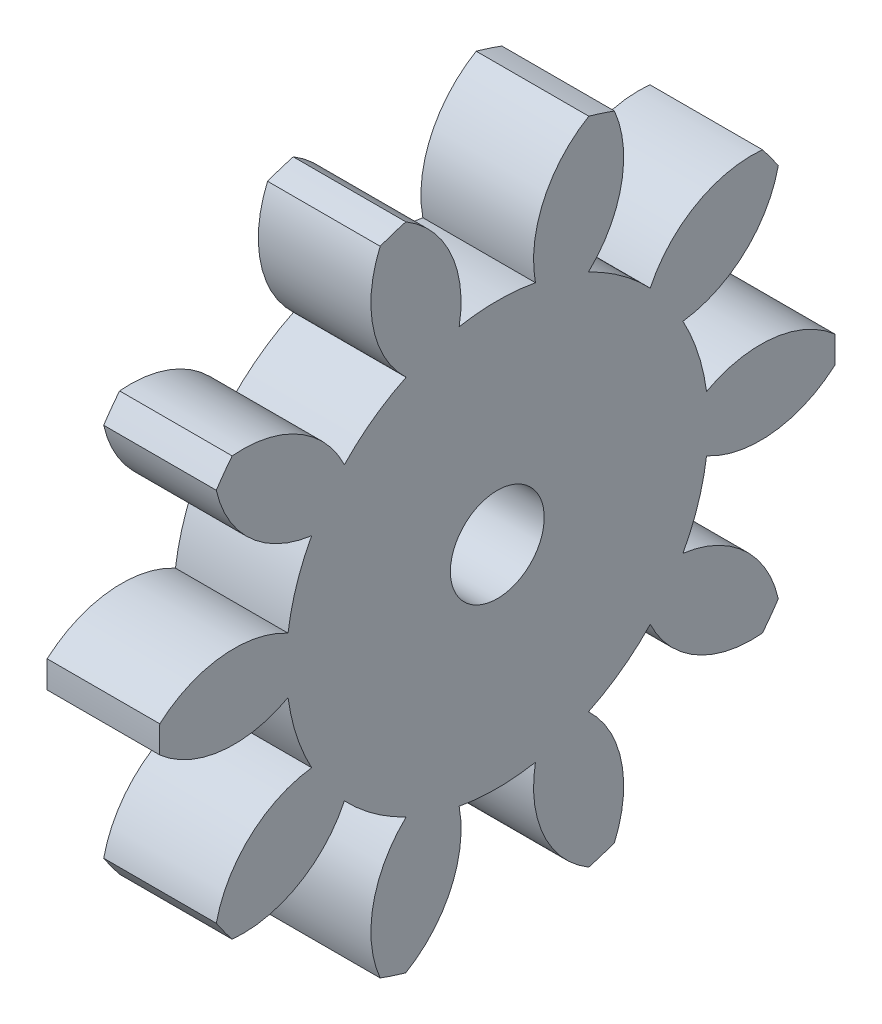
from build123d import *

# Parameters (mm, degrees)
BASPROSKE_W     = 6
BASPROSKE_H     = 18
TOOTHCUT_DEPTH  = 27.153393661
TEETHCUTS_COUNT = 10
TEETHCUTS_ANGLE = 324
BORSKE_R        = 2.5
BORE_DEPTH      = 50.0000508


with BuildPart() as part:
    # BasProSke → Base-Revolve (revolve)
    with BuildSketch(Plane(origin=(0, 0, 0), x_dir=(1, 0, 0), z_dir=(0, 1, 0)), mode=Mode.PRIVATE) as base_revolve_sk:
        with Locations((3, 9)):
            Rectangle(BASPROSKE_W, BASPROSKE_H)
    revolve(base_revolve_sk.sketch.rotate(Axis((-10, 0, 0), (1, 0, 0)), 180), axis=Axis((-10, 0, 0), (1, 0, 0)))

    # TooCutSke → ToothCut (cut, through all)
    with BuildSketch(Plane(origin=(0, 0, 0), x_dir=(0, 0, -1), z_dir=(1, 0, 0))):
        with BuildLine():
            ThreePointArc((2.033323271, 11.063706317), (0, 11.249), (-2.033323271, 11.063706317))
            ThreePointArc((-2.033323271, 11.063706317), (-2.474297893, 14.659068577), (-4.904241297, 17.34541618))
            ThreePointArc((-4.904241297, 17.34541618), (0, 18.0254), (4.904241297, 17.34541618))
            ThreePointArc((4.904241297, 17.34541618), (2.474297893, 14.659068577), (2.033323271, 11.063706317))
        make_face()
    toothcut = extrude(amount=TOOTHCUT_DEPTH, mode=Mode.SUBTRACT)

    # TeethCuts: ToothCut ×10 about axis
    teethcuts_axis = Axis((-10, 0, 0), (1, 0, 0))
    for i in range(1, TEETHCUTS_COUNT):
        add(toothcut.rotate(teethcuts_axis, i * TEETHCUTS_ANGLE / (TEETHCUTS_COUNT - 1)), mode=Mode.SUBTRACT)

    # BorSke → Bore (cut, symmetric)
    with BuildSketch(Plane(origin=(0, 0, 0), x_dir=(0, 0, -1), z_dir=(1, 0, 0))):
        with Locations(Location((0, 0, 0), (0, 0, 180))):
            Circle(BORSKE_R)
    extrude(amount=BORE_DEPTH, both=True, mode=Mode.SUBTRACT)


solid = part.part
